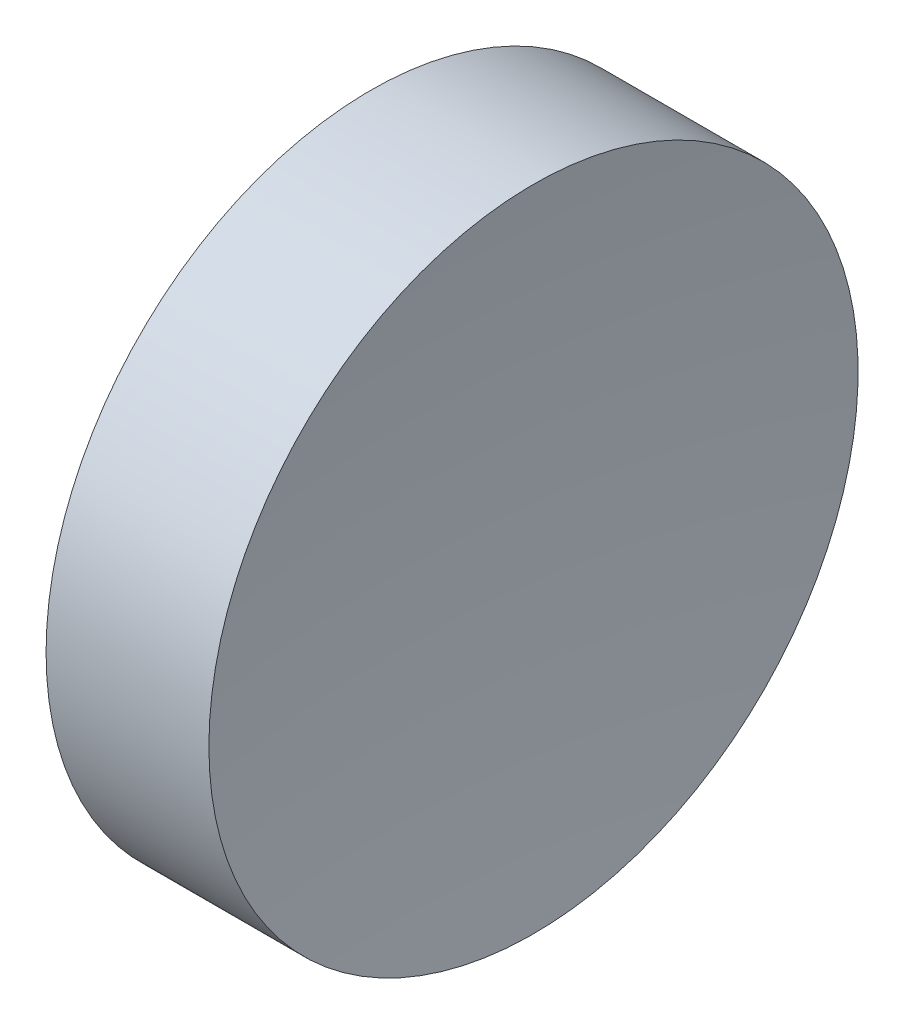
from build123d import *


with BuildPart() as part:
    # 草图1 → 旋转1 (revolve)
    with BuildSketch(Plane(origin=(0, 0, 0), x_dir=(1, 0, 0), z_dir=(0, 1, 0)), mode=Mode.PRIVATE) as revolve_1_sk:
        with BuildLine():
            Line((0, 0), (2.78, 0))
            ThreePointArc((2.78, 0), (2.881318692, 3.181446801), (3.18486415, 6.35))
            Line((3.18486415, 6.35), (0, 6.35))
            Line((0, 6.35), (0, 0))
        make_face()
    revolve(revolve_1_sk.sketch.rotate(Axis((0, 0, 0), (1, 0, 0)), 180), axis=Axis((0, 0, 0), (1, 0, 0)))  # turned: the seam where the file's is


solid = part.part
